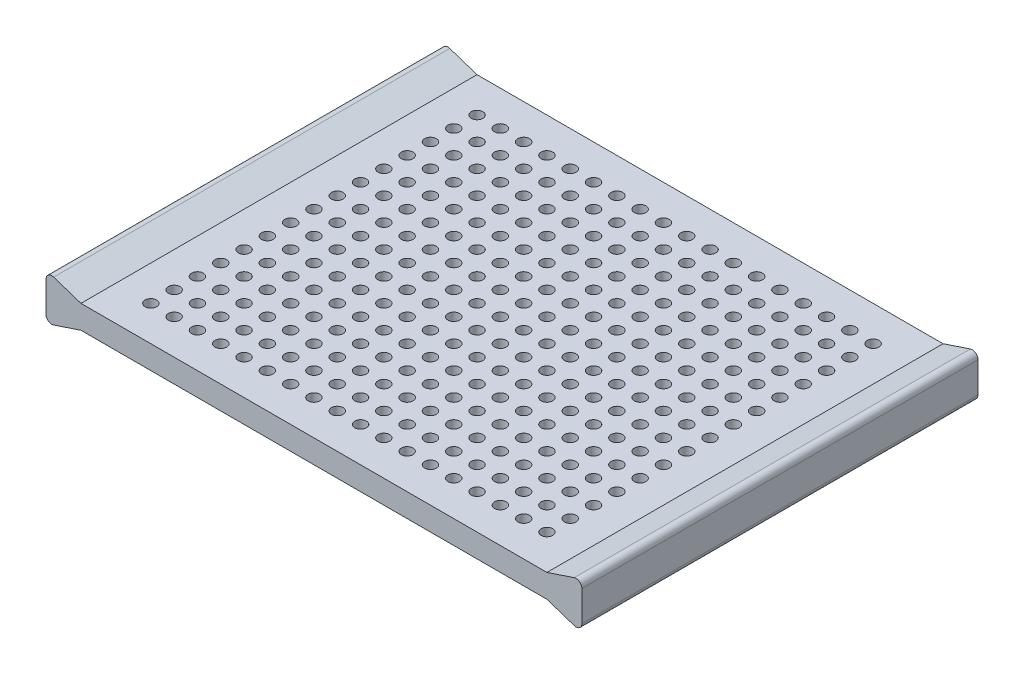
from build123d import *

# Parameters (mm, degrees)
SKETCH1_W               = 200
SKETCH1_H               = 10
MESH_BLOCK_DEPTH        = 170
SKETCH2_R               = 2.5
MESH_HOLES_DEPTH        = 11
LOCKING_MECHANISM_DEPTH = 170


with BuildPart() as part:
    # Sketch1 → Mesh Block (new body)
    with BuildSketch(Plane.XY):
        with Locations((100, 5)):
            Rectangle(SKETCH1_W, SKETCH1_H)
    extrude(amount=MESH_BLOCK_DEPTH)

    # Sketch2 → Mesh Holes (cut, through all)
    with BuildSketch(Plane(origin=(0, 10, 0), x_dir=(1, 0, 0), z_dir=(0, 1, 0))):
        with Locations((15, -155)):
            Circle(SKETCH2_R)
        with Locations((25, -155)):
            Circle(SKETCH2_R)
        with Locations((35, -155)):
            Circle(SKETCH2_R)
        with Locations((45, -155)):
            Circle(SKETCH2_R)
        with Locations((55, -155)):
            Circle(SKETCH2_R)
        with Locations((65, -155)):
            Circle(SKETCH2_R)
        with Locations((75, -155)):
            Circle(SKETCH2_R)
        with Locations((85, -155)):
            Circle(SKETCH2_R)
        with Locations((95, -155)):
            Circle(SKETCH2_R)
        with Locations((105, -155)):
            Circle(SKETCH2_R)
        with Locations((115, -155)):
            Circle(SKETCH2_R)
        with Locations((125, -155)):
            Circle(SKETCH2_R)
        with Locations((135, -155)):
            Circle(SKETCH2_R)
        with Locations((145, -155)):
            Circle(SKETCH2_R)
        with Locations((155, -155)):
            Circle(SKETCH2_R)
        with Locations((165, -155)):
            Circle(SKETCH2_R)
        with Locations((175, -155)):
            Circle(SKETCH2_R)
        with Locations((185, -155)):
            Circle(SKETCH2_R)
        with Locations((15, -145)):
            Circle(SKETCH2_R)
        with Locations((185, -145)):
            Circle(SKETCH2_R)
        with Locations((175, -145)):
            Circle(SKETCH2_R)
        with Locations((165, -145)):
            Circle(SKETCH2_R)
        with Locations((155, -145)):
            Circle(SKETCH2_R)
        with Locations((145, -145)):
            Circle(SKETCH2_R)
        with Locations((135, -145)):
            Circle(SKETCH2_R)
        with Locations((125, -145)):
            Circle(SKETCH2_R)
        with Locations((115, -145)):
            Circle(SKETCH2_R)
        with Locations((105, -145)):
            Circle(SKETCH2_R)
        with Locations((25, -145)):
            Circle(SKETCH2_R)
        with Locations((35, -145)):
            Circle(SKETCH2_R)
        with Locations((45, -145)):
            Circle(SKETCH2_R)
        with Locations((55, -145)):
            Circle(SKETCH2_R)
        with Locations((65, -145)):
            Circle(SKETCH2_R)
        with Locations((75, -145)):
            Circle(SKETCH2_R)
        with Locations((85, -145)):
            Circle(SKETCH2_R)
        with Locations((95, -145)):
            Circle(SKETCH2_R)
        with Locations((15, -135)):
            Circle(SKETCH2_R)
        with Locations((185, -135)):
            Circle(SKETCH2_R)
        with Locations((175, -135)):
            Circle(SKETCH2_R)
        with Locations((165, -135)):
            Circle(SKETCH2_R)
        with Locations((155, -135)):
            Circle(SKETCH2_R)
        with Locations((145, -135)):
            Circle(SKETCH2_R)
        with Locations((135, -135)):
            Circle(SKETCH2_R)
        with Locations((125, -135)):
            Circle(SKETCH2_R)
        with Locations((115, -135)):
            Circle(SKETCH2_R)
        with Locations((105, -135)):
            Circle(SKETCH2_R)
        with Locations((25, -135)):
            Circle(SKETCH2_R)
        with Locations((35, -135)):
            Circle(SKETCH2_R)
        with Locations((45, -135)):
            Circle(SKETCH2_R)
        with Locations((55, -135)):
            Circle(SKETCH2_R)
        with Locations((65, -135)):
            Circle(SKETCH2_R)
        with Locations((75, -135)):
            Circle(SKETCH2_R)
        with Locations((85, -135)):
            Circle(SKETCH2_R)
        with Locations((95, -135)):
            Circle(SKETCH2_R)
        with Locations((15, -125)):
            Circle(SKETCH2_R)
        with Locations((185, -125)):
            Circle(SKETCH2_R)
        with Locations((175, -125)):
            Circle(SKETCH2_R)
        with Locations((165, -125)):
            Circle(SKETCH2_R)
        with Locations((155, -125)):
            Circle(SKETCH2_R)
        with Locations((145, -125)):
            Circle(SKETCH2_R)
        with Locations((135, -125)):
            Circle(SKETCH2_R)
        with Locations((125, -125)):
            Circle(SKETCH2_R)
        with Locations((115, -125)):
            Circle(SKETCH2_R)
        with Locations((105, -125)):
            Circle(SKETCH2_R)
        with Locations((25, -125)):
            Circle(SKETCH2_R)
        with Locations((35, -125)):
            Circle(SKETCH2_R)
        with Locations((45, -125)):
            Circle(SKETCH2_R)
        with Locations((55, -125)):
            Circle(SKETCH2_R)
        with Locations((65, -125)):
            Circle(SKETCH2_R)
        with Locations((75, -125)):
            Circle(SKETCH2_R)
        with Locations((85, -125)):
            Circle(SKETCH2_R)
        with Locations((95, -125)):
            Circle(SKETCH2_R)
        with Locations((15, -115)):
            Circle(SKETCH2_R)
        with Locations((185, -115)):
            Circle(SKETCH2_R)
        with Locations((175, -115)):
            Circle(SKETCH2_R)
        with Locations((165, -115)):
            Circle(SKETCH2_R)
        with Locations((155, -115)):
            Circle(SKETCH2_R)
        with Locations((145, -115)):
            Circle(SKETCH2_R)
        with Locations((135, -115)):
            Circle(SKETCH2_R)
        with Locations((125, -115)):
            Circle(SKETCH2_R)
        with Locations((115, -115)):
            Circle(SKETCH2_R)
        with Locations((105, -115)):
            Circle(SKETCH2_R)
        with Locations((25, -115)):
            Circle(SKETCH2_R)
        with Locations((35, -115)):
            Circle(SKETCH2_R)
        with Locations((45, -115)):
            Circle(SKETCH2_R)
        with Locations((55, -115)):
            Circle(SKETCH2_R)
        with Locations((65, -115)):
            Circle(SKETCH2_R)
        with Locations((75, -115)):
            Circle(SKETCH2_R)
        with Locations((85, -115)):
            Circle(SKETCH2_R)
        with Locations((95, -115)):
            Circle(SKETCH2_R)
        with Locations((15, -105)):
            Circle(SKETCH2_R)
        with Locations((185, -105)):
            Circle(SKETCH2_R)
        with Locations((175, -105)):
            Circle(SKETCH2_R)
        with Locations((165, -105)):
            Circle(SKETCH2_R)
        with Locations((155, -105)):
            Circle(SKETCH2_R)
        with Locations((145, -105)):
            Circle(SKETCH2_R)
        with Locations((135, -105)):
            Circle(SKETCH2_R)
        with Locations((125, -105)):
            Circle(SKETCH2_R)
        with Locations((115, -105)):
            Circle(SKETCH2_R)
        with Locations((105, -105)):
            Circle(SKETCH2_R)
        with Locations((25, -105)):
            Circle(SKETCH2_R)
        with Locations((35, -105)):
            Circle(SKETCH2_R)
        with Locations((45, -105)):
            Circle(SKETCH2_R)
        with Locations((55, -105)):
            Circle(SKETCH2_R)
        with Locations((65, -105)):
            Circle(SKETCH2_R)
        with Locations((75, -105)):
            Circle(SKETCH2_R)
        with Locations((85, -105)):
            Circle(SKETCH2_R)
        with Locations((95, -105)):
            Circle(SKETCH2_R)
        with Locations((15, -95)):
            Circle(SKETCH2_R)
        with Locations((185, -95)):
            Circle(SKETCH2_R)
        with Locations((175, -95)):
            Circle(SKETCH2_R)
        with Locations((165, -95)):
            Circle(SKETCH2_R)
        with Locations((155, -95)):
            Circle(SKETCH2_R)
        with Locations((145, -95)):
            Circle(SKETCH2_R)
        with Locations((135, -95)):
            Circle(SKETCH2_R)
        with Locations((125, -95)):
            Circle(SKETCH2_R)
        with Locations((115, -95)):
            Circle(SKETCH2_R)
        with Locations((105, -95)):
            Circle(SKETCH2_R)
        with Locations((25, -95)):
            Circle(SKETCH2_R)
        with Locations((35, -95)):
            Circle(SKETCH2_R)
        with Locations((45, -95)):
            Circle(SKETCH2_R)
        with Locations((55, -95)):
            Circle(SKETCH2_R)
        with Locations((65, -95)):
            Circle(SKETCH2_R)
        with Locations((75, -95)):
            Circle(SKETCH2_R)
        with Locations((85, -95)):
            Circle(SKETCH2_R)
        with Locations((95, -95)):
            Circle(SKETCH2_R)
        with Locations((15, -85)):
            Circle(SKETCH2_R)
        with Locations((185, -85)):
            Circle(SKETCH2_R)
        with Locations((175, -85)):
            Circle(SKETCH2_R)
        with Locations((165, -85)):
            Circle(SKETCH2_R)
        with Locations((155, -85)):
            Circle(SKETCH2_R)
        with Locations((145, -85)):
            Circle(SKETCH2_R)
        with Locations((135, -85)):
            Circle(SKETCH2_R)
        with Locations((125, -85)):
            Circle(SKETCH2_R)
        with Locations((115, -85)):
            Circle(SKETCH2_R)
        with Locations((105, -85)):
            Circle(SKETCH2_R)
        with Locations((25, -85)):
            Circle(SKETCH2_R)
        with Locations((35, -85)):
            Circle(SKETCH2_R)
        with Locations((45, -85)):
            Circle(SKETCH2_R)
        with Locations((55, -85)):
            Circle(SKETCH2_R)
        with Locations((65, -85)):
            Circle(SKETCH2_R)
        with Locations((75, -85)):
            Circle(SKETCH2_R)
        with Locations((85, -85)):
            Circle(SKETCH2_R)
        with Locations((95, -85)):
            Circle(SKETCH2_R)
        with Locations((15, -75)):
            Circle(SKETCH2_R)
        with Locations((185, -75)):
            Circle(SKETCH2_R)
        with Locations((175, -75)):
            Circle(SKETCH2_R)
        with Locations((165, -75)):
            Circle(SKETCH2_R)
        with Locations((155, -75)):
            Circle(SKETCH2_R)
        with Locations((145, -75)):
            Circle(SKETCH2_R)
        with Locations((135, -75)):
            Circle(SKETCH2_R)
        with Locations((125, -75)):
            Circle(SKETCH2_R)
        with Locations((115, -75)):
            Circle(SKETCH2_R)
        with Locations((105, -75)):
            Circle(SKETCH2_R)
        with Locations((25, -75)):
            Circle(SKETCH2_R)
        with Locations((35, -75)):
            Circle(SKETCH2_R)
        with Locations((45, -75)):
            Circle(SKETCH2_R)
        with Locations((55, -75)):
            Circle(SKETCH2_R)
        with Locations((65, -75)):
            Circle(SKETCH2_R)
        with Locations((75, -75)):
            Circle(SKETCH2_R)
        with Locations((85, -75)):
            Circle(SKETCH2_R)
        with Locations((95, -75)):
            Circle(SKETCH2_R)
        with Locations((15, -65)):
            Circle(SKETCH2_R)
        with Locations((185, -65)):
            Circle(SKETCH2_R)
        with Locations((175, -65)):
            Circle(SKETCH2_R)
        with Locations((165, -65)):
            Circle(SKETCH2_R)
        with Locations((155, -65)):
            Circle(SKETCH2_R)
        with Locations((145, -65)):
            Circle(SKETCH2_R)
        with Locations((135, -65)):
            Circle(SKETCH2_R)
        with Locations((125, -65)):
            Circle(SKETCH2_R)
        with Locations((115, -65)):
            Circle(SKETCH2_R)
        with Locations((105, -65)):
            Circle(SKETCH2_R)
        with Locations((25, -65)):
            Circle(SKETCH2_R)
        with Locations((35, -65)):
            Circle(SKETCH2_R)
        with Locations((45, -65)):
            Circle(SKETCH2_R)
        with Locations((55, -65)):
            Circle(SKETCH2_R)
        with Locations((65, -65)):
            Circle(SKETCH2_R)
        with Locations((75, -65)):
            Circle(SKETCH2_R)
        with Locations((85, -65)):
            Circle(SKETCH2_R)
        with Locations((95, -65)):
            Circle(SKETCH2_R)
        with Locations((15, -55)):
            Circle(SKETCH2_R)
        with Locations((25, -55)):
            Circle(SKETCH2_R)
        with Locations((35, -55)):
            Circle(SKETCH2_R)
        with Locations((45, -55)):
            Circle(SKETCH2_R)
        with Locations((55, -55)):
            Circle(SKETCH2_R)
        with Locations((65, -55)):
            Circle(SKETCH2_R)
        with Locations((75, -55)):
            Circle(SKETCH2_R)
        with Locations((85, -55)):
            Circle(SKETCH2_R)
        with Locations((95, -55)):
            Circle(SKETCH2_R)
        with Locations((105, -55)):
            Circle(SKETCH2_R)
        with Locations((115, -55)):
            Circle(SKETCH2_R)
        with Locations((125, -55)):
            Circle(SKETCH2_R)
        with Locations((135, -55)):
            Circle(SKETCH2_R)
        with Locations((145, -55)):
            Circle(SKETCH2_R)
        with Locations((155, -55)):
            Circle(SKETCH2_R)
        with Locations((165, -55)):
            Circle(SKETCH2_R)
        with Locations((175, -55)):
            Circle(SKETCH2_R)
        with Locations((185, -55)):
            Circle(SKETCH2_R)
        with Locations((15, -45)):
            Circle(SKETCH2_R)
        with Locations((25, -45)):
            Circle(SKETCH2_R)
        with Locations((35, -45)):
            Circle(SKETCH2_R)
        with Locations((45, -45)):
            Circle(SKETCH2_R)
        with Locations((55, -45)):
            Circle(SKETCH2_R)
        with Locations((65, -45)):
            Circle(SKETCH2_R)
        with Locations((75, -45)):
            Circle(SKETCH2_R)
        with Locations((85, -45)):
            Circle(SKETCH2_R)
        with Locations((95, -45)):
            Circle(SKETCH2_R)
        with Locations((105, -45)):
            Circle(SKETCH2_R)
        with Locations((115, -45)):
            Circle(SKETCH2_R)
        with Locations((125, -45)):
            Circle(SKETCH2_R)
        with Locations((135, -45)):
            Circle(SKETCH2_R)
        with Locations((145, -45)):
            Circle(SKETCH2_R)
        with Locations((155, -45)):
            Circle(SKETCH2_R)
        with Locations((165, -45)):
            Circle(SKETCH2_R)
        with Locations((175, -45)):
            Circle(SKETCH2_R)
        with Locations((185, -45)):
            Circle(SKETCH2_R)
        with Locations((15, -35)):
            Circle(SKETCH2_R)
        with Locations((25, -35)):
            Circle(SKETCH2_R)
        with Locations((35, -35)):
            Circle(SKETCH2_R)
        with Locations((45, -35)):
            Circle(SKETCH2_R)
        with Locations((55, -35)):
            Circle(SKETCH2_R)
        with Locations((65, -35)):
            Circle(SKETCH2_R)
        with Locations((75, -35)):
            Circle(SKETCH2_R)
        with Locations((85, -35)):
            Circle(SKETCH2_R)
        with Locations((95, -35)):
            Circle(SKETCH2_R)
        with Locations((105, -35)):
            Circle(SKETCH2_R)
        with Locations((115, -35)):
            Circle(SKETCH2_R)
        with Locations((125, -35)):
            Circle(SKETCH2_R)
        with Locations((135, -35)):
            Circle(SKETCH2_R)
        with Locations((145, -35)):
            Circle(SKETCH2_R)
        with Locations((155, -35)):
            Circle(SKETCH2_R)
        with Locations((165, -35)):
            Circle(SKETCH2_R)
        with Locations((175, -35)):
            Circle(SKETCH2_R)
        with Locations((185, -35)):
            Circle(SKETCH2_R)
        with Locations((15, -25)):
            Circle(SKETCH2_R)
        with Locations((25, -25)):
            Circle(SKETCH2_R)
        with Locations((35, -25)):
            Circle(SKETCH2_R)
        with Locations((45, -25)):
            Circle(SKETCH2_R)
        with Locations((55, -25)):
            Circle(SKETCH2_R)
        with Locations((65, -25)):
            Circle(SKETCH2_R)
        with Locations((75, -25)):
            Circle(SKETCH2_R)
        with Locations((85, -25)):
            Circle(SKETCH2_R)
        with Locations((95, -25)):
            Circle(SKETCH2_R)
        with Locations((105, -25)):
            Circle(SKETCH2_R)
        with Locations((115, -25)):
            Circle(SKETCH2_R)
        with Locations((125, -25)):
            Circle(SKETCH2_R)
        with Locations((135, -25)):
            Circle(SKETCH2_R)
        with Locations((145, -25)):
            Circle(SKETCH2_R)
        with Locations((155, -25)):
            Circle(SKETCH2_R)
        with Locations((165, -25)):
            Circle(SKETCH2_R)
        with Locations((175, -25)):
            Circle(SKETCH2_R)
        with Locations((185, -25)):
            Circle(SKETCH2_R)
        with Locations((15, -15)):
            Circle(SKETCH2_R)
        with Locations((25, -15)):
            Circle(SKETCH2_R)
        with Locations((35, -15)):
            Circle(SKETCH2_R)
        with Locations((45, -15)):
            Circle(SKETCH2_R)
        with Locations((55, -15)):
            Circle(SKETCH2_R)
        with Locations((65, -15)):
            Circle(SKETCH2_R)
        with Locations((75, -15)):
            Circle(SKETCH2_R)
        with Locations((85, -15)):
            Circle(SKETCH2_R)
        with Locations((95, -15)):
            Circle(SKETCH2_R)
        with Locations((105, -15)):
            Circle(SKETCH2_R)
        with Locations((115, -15)):
            Circle(SKETCH2_R)
        with Locations((125, -15)):
            Circle(SKETCH2_R)
        with Locations((135, -15)):
            Circle(SKETCH2_R)
        with Locations((145, -15)):
            Circle(SKETCH2_R)
        with Locations((155, -15)):
            Circle(SKETCH2_R)
        with Locations((165, -15)):
            Circle(SKETCH2_R)
        with Locations((175, -15)):
            Circle(SKETCH2_R)
        with Locations((185, -15)):
            Circle(SKETCH2_R)
    extrude(amount=-MESH_HOLES_DEPTH, mode=Mode.SUBTRACT)

    # Sketch3 → Locking Mechanism (add)
    with BuildSketch(Plane.XY.offset(170)):
        with BuildLine():
            Line((0, 0), (-11.709430585, -3.903143528))
            ThreePointArc((-11.709430585, -3.903143528), (-13.961775712, -3.559540746), (-15, -1.531435283))
            Line((-15, -1.531435283), (-15, 11.531435283))
            ThreePointArc((-15, 11.531435283), (-13.961775712, 13.559540746), (-11.709430585, 13.903143528))
            Line((-11.709430585, 13.903143528), (0, 10))
            Line((0, 10), (0, 0))
        make_face()
        with BuildLine():
            Line((211.709430585, 13.903143528), (200, 10))
            Line((200, 10), (200, 0))
            Line((200, 0), (211.709430585, -3.903143528))
            ThreePointArc((211.709430585, -3.903143528), (213.961775712, -3.559540746), (215, -1.531435283))
            Line((215, -1.531435283), (215, 11.531435283))
            ThreePointArc((215, 11.531435283), (213.961775712, 13.559540746), (211.709430585, 13.903143528))
        make_face()
    extrude(amount=-LOCKING_MECHANISM_DEPTH)


solid = part.part
